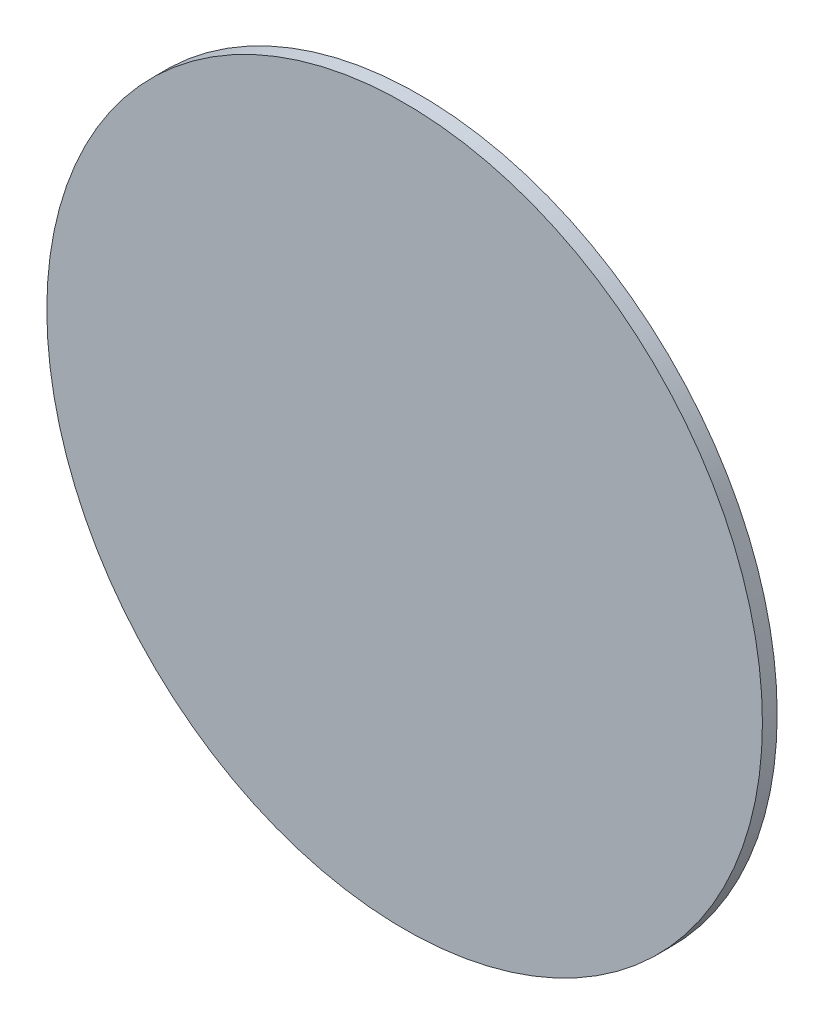
from build123d import *

# Parameters (mm, degrees)
CROQUIS1_R              = 9.7
SALIENTE_EXTRUIR1_DEPTH = 0.4


with BuildPart() as part:
    # Croquis1 → Saliente-Extruir1 (new body)
    with BuildSketch(Plane.XY):
        Circle(CROQUIS1_R)
    extrude(amount=SALIENTE_EXTRUIR1_DEPTH)


solid = part.part
